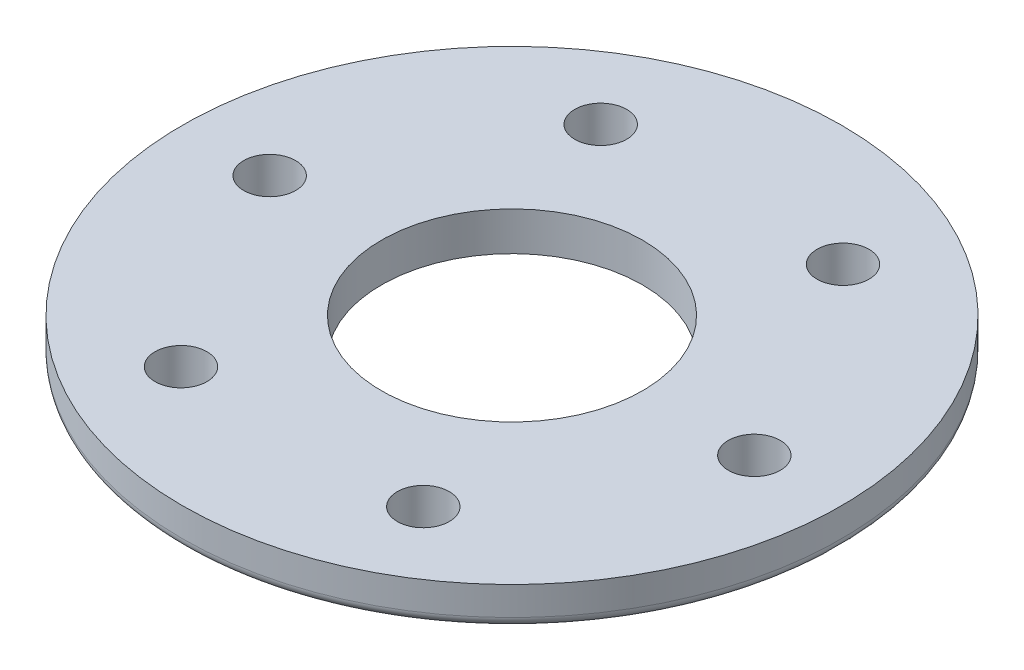
from build123d import *

# Parameters (mm, degrees)
SKETCH1_W                      = 32.385
SKETCH1_H                      = 3.81
F_7_0_201_DIAMETER_HOLE1_D     = 5.1054
F_7_0_201_DIAMETER_HOLE1_DEPTH = 3.81
HOLE1_D                        = 25.654
HOLE1_DEPTH                    = 3.81
FILLET1_R                      = 1


with BuildPart() as part:
    # Sketch1 → Revolve1 (revolve)
    with BuildSketch(Plane(origin=(0, 0, 0), x_dir=(-1, 0, 0), z_dir=(0, 0, -1))):
        with Locations((-16.1925, 1.905)):
            Rectangle(SKETCH1_W, SKETCH1_H)
    revolve(axis=Axis((0, 0, 0), (0, 1, 0)))

    # #7 (0.201) Diameter Hole1
    with Locations(Plane(origin=(0, 0, 0), x_dir=(-1, 0, 0), z_dir=(0, -1, 0))):
        with Locations((11.90625, 20.622229928), (-11.90625, 20.622229928), (-23.8125, 0), (-11.90625, -20.622229928), (11.90625, -20.622229928), (23.8125, 0)):
            Hole(F_7_0_201_DIAMETER_HOLE1_D / 2, depth=F_7_0_201_DIAMETER_HOLE1_DEPTH)

    # Hole1
    with Locations(Plane(origin=(0, 0, 0), x_dir=(-1, 0, 0), z_dir=(0, -1, 0))):
        with Locations((0, 0)):
            Hole(HOLE1_D / 2, depth=HOLE1_DEPTH)

    # Fillet1
    fillet1_edges = [part.edges().sort_by_distance(p)[0] for p in [
        (-32.385, 0, 0),
    ]]
    fillet(fillet1_edges, radius=FILLET1_R)


solid = part.part
